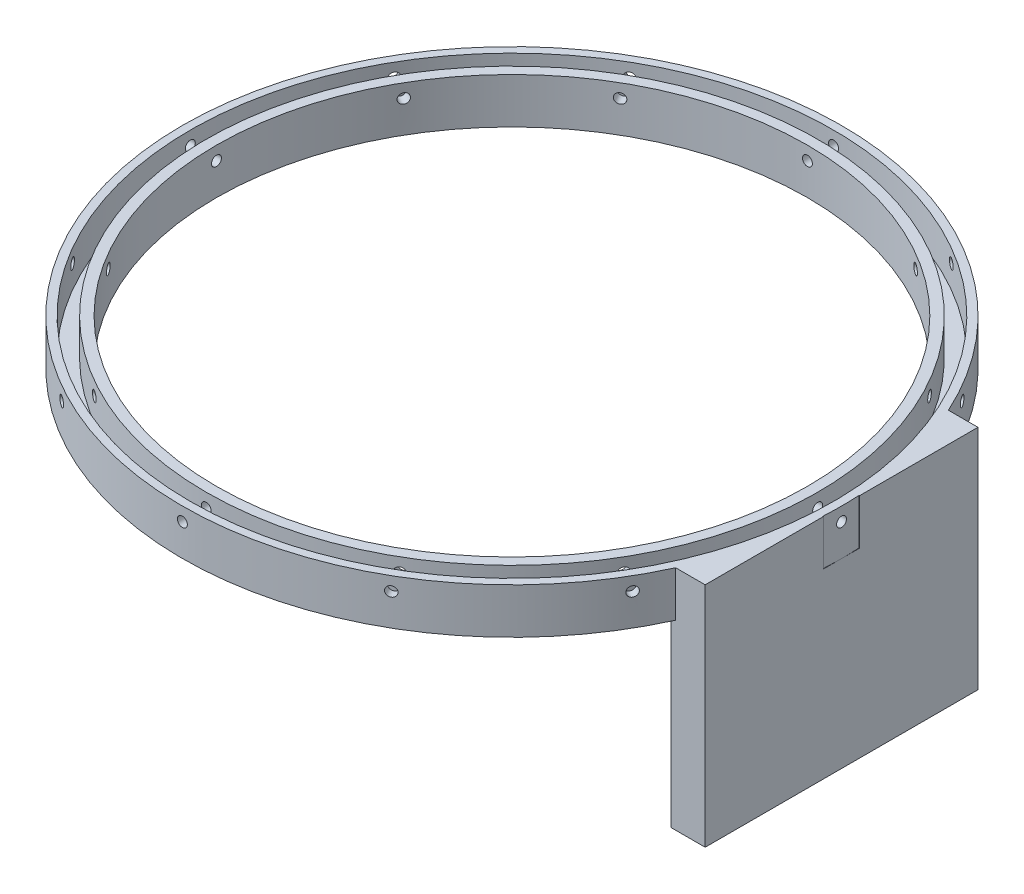
from build123d import *

# Parameters (mm, degrees)
SKETCH1_R           = 92.075
SKETCH1_R_2         = 82.55
BOSS_EXTRUDE1_DEPTH = 12.7
SKETCH2_R           = 89.8525
SKETCH2_R_2         = 85.4075
CUT_EXTRUDE1_DEPTH  = 10.16
CUT_EXTRUDE2_START  = -92.075
SKETCH3_R           = 1.3843
CUT_EXTRUDE2_DEPTH  = 9.536608
CIRPATTERN1_COUNT   = 12
SKETCH4_W           = 9.525
SKETCH4_H           = 76.2
BOSS_EXTRUDE2_DEPTH = 50.8
BOSS_EXTRUDE4_DEPTH = 12.7


with BuildPart() as part:
    # Sketch1 → Boss-Extrude1 (new body)
    with BuildSketch(Plane(origin=(0, 0, 0), x_dir=(1, 0, 0), z_dir=(0, 1, 0))):
        Circle(SKETCH1_R)
        Circle(SKETCH1_R_2, mode=Mode.SUBTRACT)
    extrude(amount=BOSS_EXTRUDE1_DEPTH)

    # Sketch2 → Cut-Extrude1 (cut)
    with BuildSketch(Plane(origin=(0, 12.7, 0), x_dir=(1, 0, 0), z_dir=(0, 1, 0))):
        Circle(SKETCH2_R)
        Circle(SKETCH2_R_2, mode=Mode.SUBTRACT)
    extrude(amount=-CUT_EXTRUDE1_DEPTH, mode=Mode.SUBTRACT)

    # Sketch3 → Cut-Extrude2 (cut)
    with BuildSketch(Plane.XY.offset(CUT_EXTRUDE2_START)):
        with Locations((0, 8.89)):
            Circle(SKETCH3_R)
    cut_extrude2 = extrude(amount=CUT_EXTRUDE2_DEPTH, mode=Mode.SUBTRACT)

    # CirPattern1: Cut-Extrude2 ×12 about axis
    cirpattern1_axis = Axis((0, 12.7, 0), (0, 1, 0))
    for i in range(1, CIRPATTERN1_COUNT):
        add(cut_extrude2.rotate(cirpattern1_axis, i * 360 / CIRPATTERN1_COUNT), mode=Mode.SUBTRACT)

    # Sketch4 → Boss-Extrude2 (add)
    with BuildSketch(Plane(origin=(0, 0, 0), x_dir=(-1, 0, 0), z_dir=(0, -1, 0))):
        with Locations((-87.3125, 0)):
            Rectangle(SKETCH4_W, SKETCH4_H)
    extrude(amount=BOSS_EXTRUDE2_DEPTH)

    # Sketch5 → Boss-Extrude4 (add)
    with BuildSketch(Plane(origin=(0, 0, 0), x_dir=(1, 0, 0), z_dir=(0, 1, 0))):
        with BuildLine():
            Line((92.075, -5.08), (91.934755262, -5.08))
            ThreePointArc((91.934755262, -5.08), (89.416021883, -21.967718489), (83.822405269, -38.1))
            Line((83.822405269, -38.1), (92.075, -38.1))
            Line((92.075, -38.1), (92.075, -5.08))
        make_face()
        with BuildLine():
            Line((92.075, 5.08), (91.934755262, 5.08))
            ThreePointArc((91.934755262, 5.08), (89.416021883, 21.967718489), (83.822405269, 38.1))
            Line((83.822405269, 38.1), (92.075, 38.1))
            Line((92.075, 38.1), (92.075, 5.08))
        make_face()
    extrude(amount=BOSS_EXTRUDE4_DEPTH)


solid = part.part
